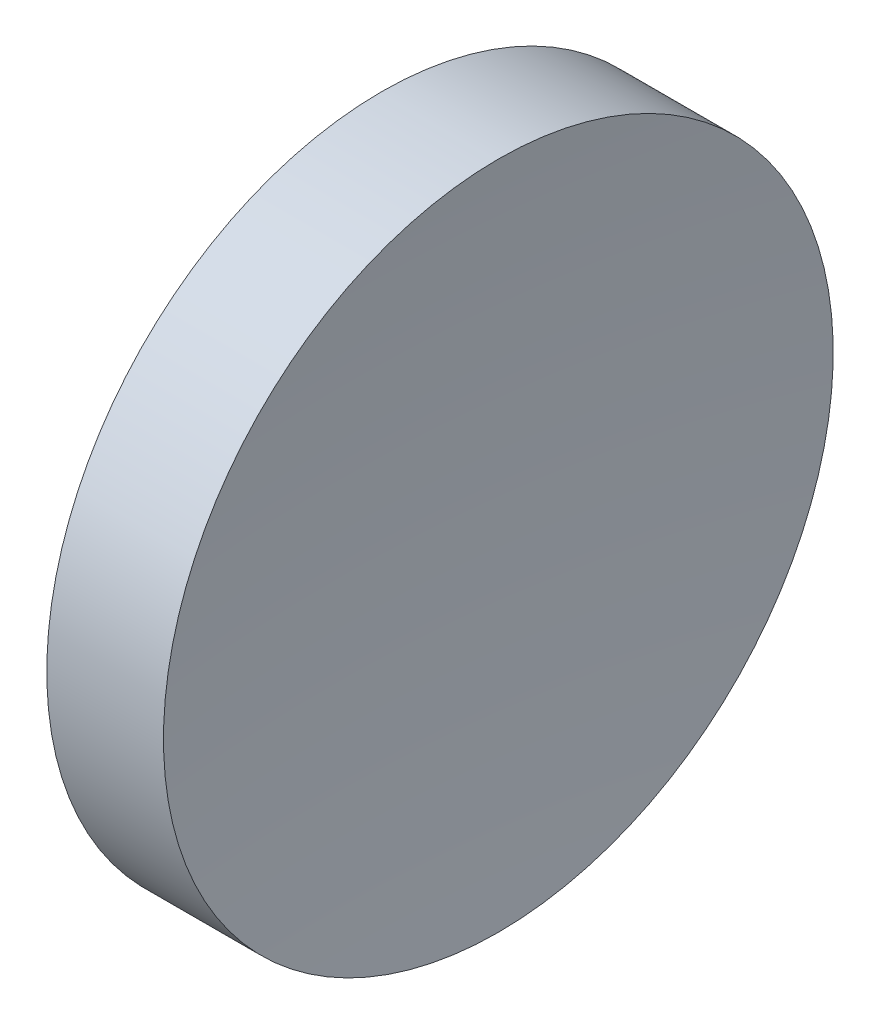
from build123d import *


with BuildPart() as part:
    # 草图1 → 旋转1 (revolve)
    with BuildSketch(Plane.XY, mode=Mode.PRIVATE) as revolve_1_sk:
        with BuildLine():
            Line((22.424232054, 13.031126091), (22.424232054, 18.031126091))
            Line((22.424232054, 18.031126091), (24.166862471, 18.031126091))
            ThreePointArc((24.166862471, 18.031126091), (23.984925325, 15.534067837), (23.924232054, 13.031126091))
            Line((23.924232054, 13.031126091), (22.424232054, 13.031126091))
        make_face()
    revolve(revolve_1_sk.sketch.rotate(Axis((21.505975118, 13.031126091, 0), (1, 0, 0)), 180), axis=Axis((21.505975118, 13.031126091, 0), (1, 0, 0)))  # turned: the seam where the file's is


solid = part.part
